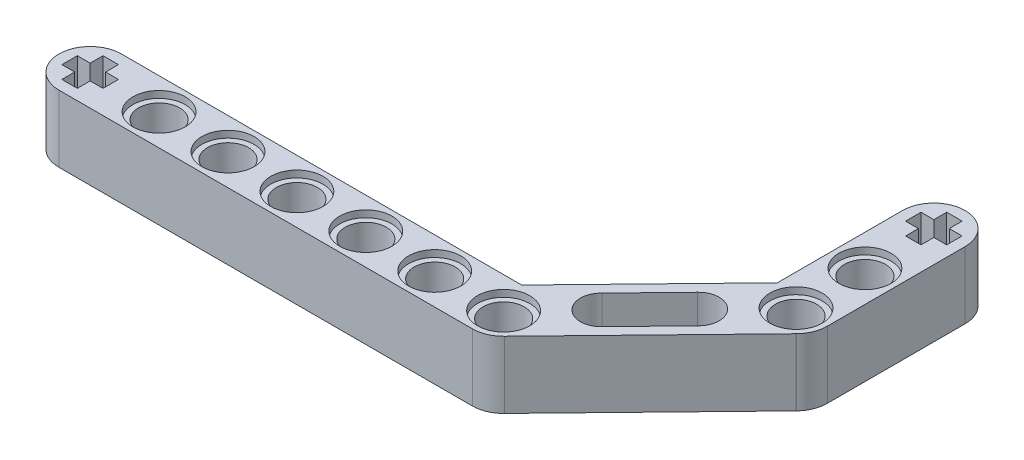
from build123d import *

# Parameters (mm, degrees)
SKETCH1_R           = 2.4
BOSS_EXTRUDE1_DEPTH = 7.8
SKETCH2_R           = 3.05
CUT_EXTRUDE1_DEPTH  = 0.8
SKETCH3_R           = 3.05
CUT_EXTRUDE2_DEPTH  = 0.8


with BuildPart() as part:
    # Sketch1 → Boss-Extrude1 (new body)
    with BuildSketch(Plane(origin=(0, 0, 0), x_dir=(1, 0, 0), z_dir=(0, 1, 0))):
        with BuildLine():
            Line((15.06695764, 3.65), (-31.62850949, 3.65))
            ThreePointArc((-31.62850949, 3.65), (-35.27850949, 0), (-31.62850949, -3.65))
            Line((-31.62850949, -3.65), (16.61149051, -3.65))
            ThreePointArc((16.61149051, -3.65), (18.033912451, -3.361430621), (19.23142074, -2.541351135))
            Line((19.23142074, -2.541351135), (35.979469964, 14.72489695))
            Line((35.979469964, 14.72489695), (36.014632418, 14.760846213))
            ThreePointArc((36.014632418, 14.760846213), (36.787004293, 15.9395566), (37.055282295, 17.323010033))
            Line((37.055282295, 17.323010033), (37.055327398, 33.403010033))
            ThreePointArc((37.055327398, 33.403010033), (33.405295822, 37.05304161), (29.755264245, 33.403010033))
            Line((29.755264245, 33.403010033), (29.755264245, 18.792472031))
            Line((29.755264245, 18.792472031), (15.06695764, 3.65))
        make_face()
        Polygon((-30.72850949, 2.4), (-30.72850949, 0.9), (-29.22850949, 0.9), (-29.22850949, -0.9), (-30.72850949, -0.9), (-30.72850949, -2.4), (-32.52850949, -2.4), (-32.52850949, -0.9), (-34.02850949, -0.9), (-34.02850949, 0.9), (-32.52850949, 0.9), (-32.52850949, 2.4), align=None, mode=Mode.SUBTRACT)
        with Locations((-23.58850949, 0)):
            Circle(SKETCH1_R, mode=Mode.SUBTRACT)
        with Locations((-15.54850949, 0)):
            Circle(SKETCH1_R, mode=Mode.SUBTRACT)
        with Locations((-7.50850949, 0)):
            Circle(SKETCH1_R, mode=Mode.SUBTRACT)
        with Locations((0.53149051, 0)):
            Circle(SKETCH1_R, mode=Mode.SUBTRACT)
        with Locations((8.57149051, 0)):
            Circle(SKETCH1_R, mode=Mode.SUBTRACT)
        with Locations((16.61149051, 0)):
            Circle(SKETCH1_R, mode=Mode.SUBTRACT)
        with BuildLine():
            ThreePointArc((23.932119463, 4.099998991), (20.490614709, 4.09600527), (20.583406202, 7.536261171))
            Line((20.583406202, 7.536261171), (26.065029385, 13.19258856))
            ThreePointArc((26.065029385, 13.19258856), (26.083897287, 13.212280453), (26.102987734, 13.231756675))
            ThreePointArc((26.102987734, 13.231756675), (29.48775233, 13.255607669), (29.530054567, 9.871023387))
            Line((29.530054567, 9.871023387), (23.932119463, 4.099998991))
        make_face(mode=Mode.SUBTRACT)
        with Locations((33.405295822, 17.323010033)):
            Circle(SKETCH1_R, mode=Mode.SUBTRACT)
        with Locations((33.405295822, 25.363010033)):
            Circle(SKETCH1_R, mode=Mode.SUBTRACT)
        Polygon((34.305295822, 35.803010033), (34.305295822, 34.303010033), (35.805295822, 34.303010033), (35.805295822, 32.503010033), (34.305295822, 32.503010033), (34.305295822, 31.003010033), (32.505295822, 31.003010033), (32.505295822, 32.503010033), (31.005295822, 32.503010033), (31.005295822, 34.303010033), (32.505295822, 34.303010033), (32.505295822, 35.803010033), align=None, mode=Mode.SUBTRACT)
    extrude(amount=BOSS_EXTRUDE1_DEPTH)

    # Sketch2 → Cut-Extrude1 (cut)
    with BuildSketch(Plane(origin=(0, 7.8, 0), x_dir=(1, 0, 0), z_dir=(0, 1, 0))):
        with Locations((-23.58850949, 0)):
            Circle(SKETCH2_R)
        with Locations((-15.54850949, 0)):
            Circle(SKETCH2_R)
        with Locations((-7.50850949, 0)):
            Circle(SKETCH2_R)
        with Locations((0.53149051, 0)):
            Circle(SKETCH2_R)
        with Locations((8.57149051, 0)):
            Circle(SKETCH2_R)
        with Locations((16.61149051, 0)):
            Circle(SKETCH2_R)
        with Locations((33.405295822, 17.323010033)):
            Circle(SKETCH2_R)
        with Locations((33.405295822, 25.363010033)):
            Circle(SKETCH2_R)
    extrude(amount=-CUT_EXTRUDE1_DEPTH, mode=Mode.SUBTRACT)

    # Sketch3 → Cut-Extrude2 (cut)
    with BuildSketch(Plane.XZ):
        with Locations((-23.55968241, 0)):
            Circle(SKETCH3_R)
        with Locations((-15.54850949, 0)):
            Circle(SKETCH3_R)
        with Locations((-7.50850949, 0)):
            Circle(SKETCH3_R)
        with Locations((0.53149051, 0)):
            Circle(SKETCH3_R)
        with Locations((8.57149051, 0)):
            Circle(SKETCH3_R)
        with Locations((16.61149051, 0)):
            Circle(SKETCH3_R)
        with Locations((33.405295822, -17.323010033)):
            Circle(SKETCH3_R)
        with Locations((33.405295822, -25.363010033)):
            Circle(SKETCH3_R)
    extrude(amount=-CUT_EXTRUDE2_DEPTH, mode=Mode.SUBTRACT)


solid = part.part
